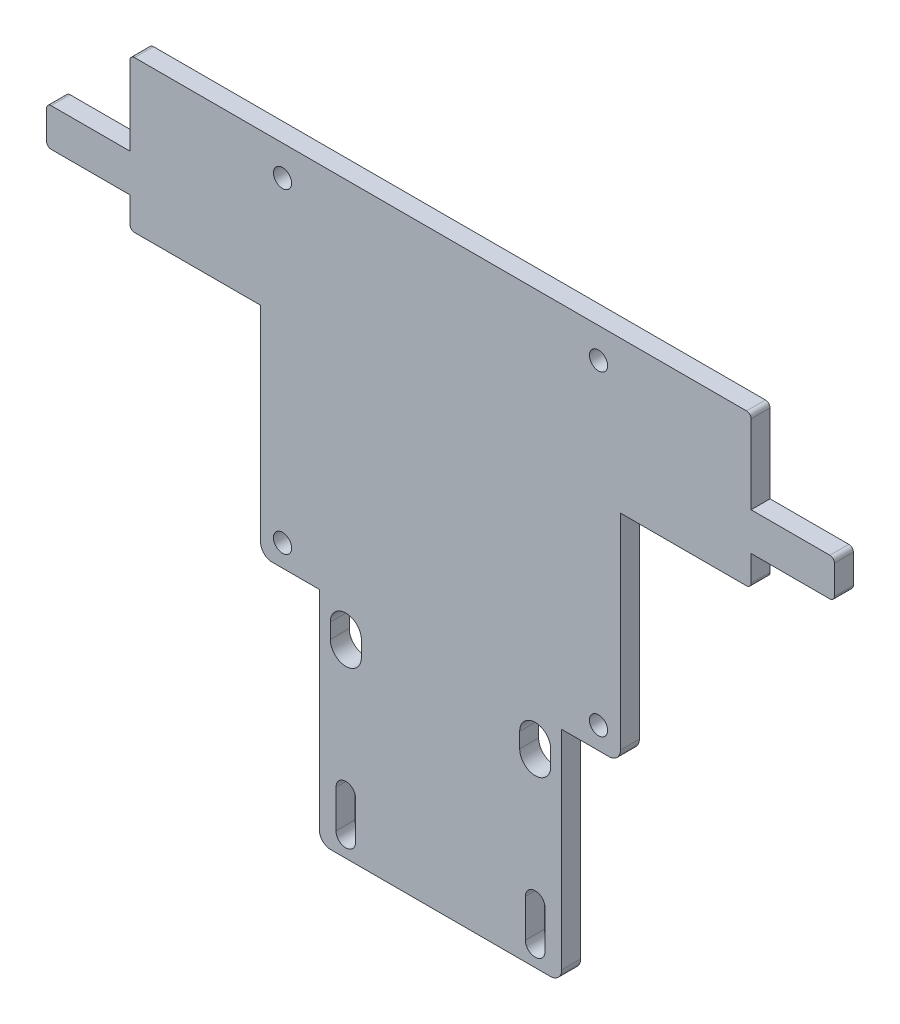
from build123d import *

# Parameters (mm, degrees)
SKETCH1_R           = 1.524
BOSS_EXTRUDE1_DEPTH = 3.175


with BuildPart() as part:
    # Sketch1 → Boss-Extrude1 (new body)
    with BuildSketch(Plane.XY):
        with BuildLine():
            Line((0.762, 0), (21.9075, 0))
            Line((21.9075, 0), (21.9075, -34.42335))
            ThreePointArc((21.9075, -34.42335), (22.465461582, -35.770388418), (23.8125, -36.32835))
            Line((23.8125, -36.32835), (31.75, -36.32835))
            Line((31.75, -36.32835), (31.75, -71.25335))
            ThreePointArc((31.75, -71.25335), (32.307961582, -72.600388418), (33.655, -73.15835))
            Line((33.655, -73.15835), (70.485, -73.15835))
            ThreePointArc((70.485, -73.15835), (71.832038418, -72.600388418), (72.39, -71.25335))
            Line((72.39, -71.25335), (72.39, -36.32835))
            Line((72.39, -36.32835), (80.3275, -36.32835))
            ThreePointArc((80.3275, -36.32835), (81.674538418, -35.770388418), (82.2325, -34.42335))
            Line((82.2325, -34.42335), (82.2325, 0))
            Line((82.2325, 0), (103.378, 0))
            ThreePointArc((103.378, 0), (103.916815367, 0.223184633), (104.14, 0.762))
            Line((104.14, 0.762), (104.14, 5.08))
            Line((104.14, 5.08), (117.348, 5.08))
            ThreePointArc((117.348, 5.08), (117.886815367, 5.303184633), (118.11, 5.842))
            Line((118.11, 5.842), (118.11, 10.668))
            ThreePointArc((118.11, 10.668), (117.886815367, 11.206815367), (117.348, 11.43))
            Line((117.348, 11.43), (104.14, 11.43))
            Line((104.14, 11.43), (104.14, 24.638))
            ThreePointArc((104.14, 24.638), (103.916815367, 25.176815367), (103.378, 25.4))
            Line((103.378, 25.4), (0.762, 25.4))
            ThreePointArc((0.762, 25.4), (0.223184633, 25.176815367), (0, 24.638))
            Line((0, 24.638), (0, 11.43))
            Line((0, 11.43), (-13.208, 11.43))
            ThreePointArc((-13.208, 11.43), (-13.746815367, 11.206815367), (-13.97, 10.668))
            Line((-13.97, 10.668), (-13.97, 5.842))
            ThreePointArc((-13.97, 5.842), (-13.746815367, 5.303184633), (-13.208, 5.08))
            Line((-13.208, 5.08), (0, 5.08))
            Line((0, 5.08), (0, 0.762))
            ThreePointArc((0, 0.762), (0.223184633, 0.223184633), (0.762, 0))
        make_face()
        with Locations((25.58415, 20.32)):
            Circle(SKETCH1_R, mode=Mode.SUBTRACT)
        with Locations((78.55585, 20.32)):
            Circle(SKETCH1_R, mode=Mode.SUBTRACT)
        with Locations((78.55585, -32.6517)):
            Circle(SKETCH1_R, mode=Mode.SUBTRACT)
        with Locations((25.58415, -32.6517)):
            Circle(SKETCH1_R, mode=Mode.SUBTRACT)
        with BuildLine():
            Line((38.7985, -40.13835), (38.7985, -42.67835))
            ThreePointArc((38.7985, -42.67835), (36.195, -45.28185), (33.5915, -42.67835))
            Line((33.5915, -42.67835), (33.5915, -40.13835))
            ThreePointArc((33.5915, -40.13835), (36.195, -37.53485), (38.7985, -40.13835))
        make_face(mode=Mode.SUBTRACT)
        with BuildLine():
            Line((70.5485, -40.13835), (70.5485, -42.67835))
            ThreePointArc((70.5485, -42.67835), (67.945, -45.28185), (65.3415, -42.67835))
            Line((65.3415, -42.67835), (65.3415, -40.13835))
            ThreePointArc((65.3415, -40.13835), (67.945, -37.53485), (70.5485, -40.13835))
        make_face(mode=Mode.SUBTRACT)
        with BuildLine():
            Line((69.595, -63.63335), (69.595, -69.98335))
            ThreePointArc((69.595, -69.98335), (67.945, -71.63335), (66.295, -69.98335))
            Line((66.295, -69.98335), (66.295, -63.63335))
            ThreePointArc((66.295, -63.63335), (67.945, -61.98335), (69.595, -63.63335))
        make_face(mode=Mode.SUBTRACT)
        with BuildLine():
            Line((37.845, -63.63335), (37.845, -69.98335))
            ThreePointArc((37.845, -69.98335), (36.195, -71.63335), (34.545, -69.98335))
            Line((34.545, -69.98335), (34.545, -63.63335))
            ThreePointArc((34.545, -63.63335), (36.195, -61.98335), (37.845, -63.63335))
        make_face(mode=Mode.SUBTRACT)
    extrude(amount=BOSS_EXTRUDE1_DEPTH)


solid = part.part
